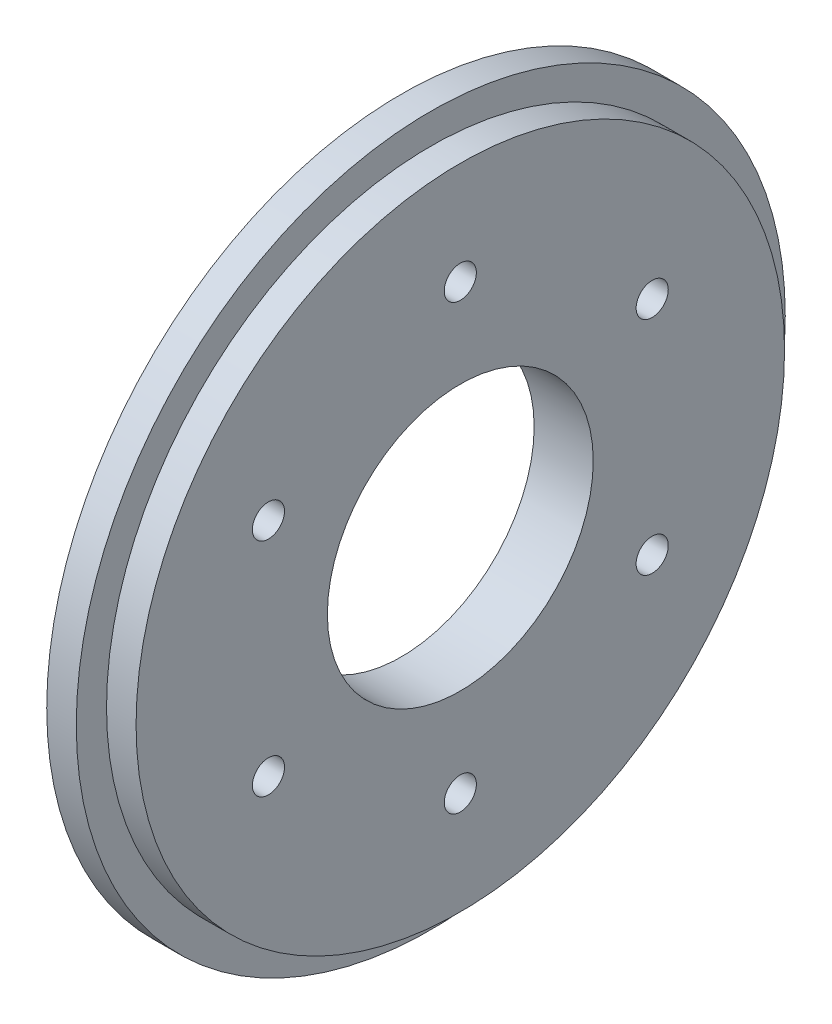
from build123d import *

# Parameters (mm, degrees)
SKETCH1_R                  = 38.1
BOSS_EXTRUDE1_DEPTH        = 6.35
SKETCH3_R                  = 38.1
SKETCH3_R_2                = 34.8488
CUT_EXTRUDE_THIN1_DEPTH    = 3.175
F_1_2_0_5_DIAMETER_HOLE1_D = 28.575
F_8_32_TAPPED_HOLE1_D      = 3.4544
CIRPATTERN1_COUNT          = 6


with BuildPart() as part:
    # Sketch1 → Boss-Extrude1 (new body)
    with BuildSketch(Plane(origin=(0, 0, 0), x_dir=(0, 0, -1), z_dir=(1, 0, 0))):
        Circle(SKETCH1_R)
    extrude(amount=BOSS_EXTRUDE1_DEPTH)

    # Sketch3 → Cut-Extrude-Thin1 (cut)
    with BuildSketch(Plane(origin=(6.35, 0, 0), x_dir=(0, 0, -1), z_dir=(1, 0, 0))):
        Circle(SKETCH3_R)
        Circle(SKETCH3_R_2, mode=Mode.SUBTRACT)
    extrude(amount=-CUT_EXTRUDE_THIN1_DEPTH, mode=Mode.SUBTRACT)

    # 1/2 (0.5) Diameter Hole1 (through all)
    with Locations(Plane(origin=(6.35, 0, 0), x_dir=(0, 0, -1), z_dir=(1, 0, 0))):
        with Locations((0, 0)):
            Hole(F_1_2_0_5_DIAMETER_HOLE1_D / 2)

    # #8-32 Tapped Hole1 (through all)
    with Locations(Plane.ZY):
        with Locations((0, 23.8125)):
            f_8_32_tapped_hole1 = Hole(F_8_32_TAPPED_HOLE1_D / 2)

    # CirPattern1: #8-32 Tapped Hole1 ×6 about axis
    cirpattern1_axis = Axis((0, 0, 0), (1, 0, 0))
    for i in range(1, CIRPATTERN1_COUNT):
        add(f_8_32_tapped_hole1.rotate(cirpattern1_axis, i * 360 / CIRPATTERN1_COUNT), mode=Mode.SUBTRACT)


solid = part.part
